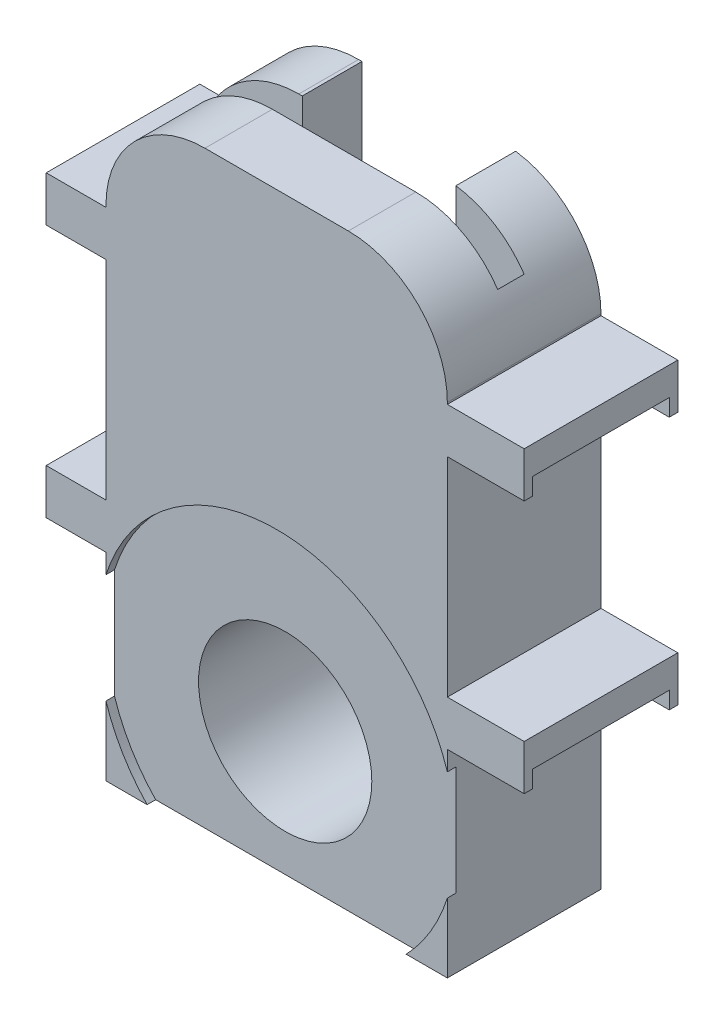
from build123d import *

# Parameters (mm, degrees)
SKETCH2_W           = 20
SKETCH2_H           = 35
BOSS_EXTRUDE1_DEPTH = 9
SKETCH3_W           = 9
SKETCH3_H           = 2.65
BOSS_EXTRUDE2_DEPTH = 14
SKETCH3_2_W         = 9
SKETCH3_2_H         = 2.65
BOSS_EXTRUDE3_DEPTH = 14
SKETCH4_R           = 5.075
CUT_EXTRUDE1_DEPTH  = 34.88300924
SKETCH5_R           = 10.5
CUT_EXTRUDE2_DEPTH  = 0.5
SKETCH7_W           = 18
SKETCH7_H           = 1.55
CUT_EXTRUDE3_DEPTH  = 22.2
SKETCH8_W           = 9
SKETCH8_H           = 3.5
CUT_EXTRUDE4_DEPTH  = 19
SKETCH9_W           = 3.2
SKETCH9_H           = 8
SKETCH9_W_2         = 4.2
CUT_EXTRUDE5_DEPTH  = 1
SKETCH10_W          = 3.2
SKETCH10_H          = 6.5
SKETCH10_W_2        = 4.2
SKETCH10_H_2        = 8
CUT_EXTRUDE6_DEPTH  = 1
CUT_EXTRUDE7_DEPTH  = 10


with BuildPart() as part:
    # Sketch2 → Boss-Extrude1 (new body)
    with BuildSketch(Plane.XY):
        with Locations((-6.829268293, 8.069105691)):
            Rectangle(SKETCH2_W, SKETCH2_H)
    extrude(amount=BOSS_EXTRUDE1_DEPTH)

    # Sketch3 → Boss-Extrude2 (add)
    with BuildSketch(Plane(origin=(-6.329268293, 0, 0), x_dir=(0, 0, -1), z_dir=(1, 0, 0))):
        with Locations((-4.5, 18.344105691)):
            Rectangle(SKETCH3_W, SKETCH3_H)
        with Locations((-4.5, 3.494105691)):
            Rectangle(SKETCH3_W, SKETCH3_H)
    extrude(amount=BOSS_EXTRUDE2_DEPTH)

    # Sketch3_2 → Boss-Extrude3 (add)
    with BuildSketch(Plane(origin=(-6.329268293, 0, 0), x_dir=(0, 0, -1), z_dir=(1, 0, 0))):
        with Locations((-4.5, 18.344105691)):
            Rectangle(SKETCH3_2_W, SKETCH3_2_H)
        with Locations((-4.5, 3.494105691)):
            Rectangle(SKETCH3_2_W, SKETCH3_2_H)
    extrude(amount=-BOSS_EXTRUDE3_DEPTH)

    # Sketch4 → Cut-Extrude1 (cut, through all)
    with BuildSketch(Plane.XY.offset(9)):
        with Locations((-6.829268293, -2.173702028)):
            Circle(SKETCH4_R)
    extrude(amount=-CUT_EXTRUDE1_DEPTH, mode=Mode.SUBTRACT)

    # Sketch5 → Cut-Extrude2 (cut)
    with BuildSketch(Plane.XY.offset(9)):
        with Locations((-6.829268293, -2.173702028)):
            Circle(SKETCH5_R)
    extrude(amount=-CUT_EXTRUDE2_DEPTH, mode=Mode.SUBTRACT)

    # Sketch7 → Cut-Extrude3 (cut)
    with BuildSketch(Plane(origin=(0, 25.569105691, 0), x_dir=(1, 0, 0), z_dir=(0, 1, 0))):
        with Locations((-6.829268293, -4.275)):
            Rectangle(SKETCH7_W, SKETCH7_H)
    extrude(amount=-CUT_EXTRUDE3_DEPTH, mode=Mode.SUBTRACT)

    # Sketch8 → Cut-Extrude4 (cut)
    with BuildSketch(Plane(origin=(0, 25.569105691, 0), x_dir=(1, 0, 0), z_dir=(0, 1, 0))):
        with Locations((-6.329268293, -1.75)):
            Rectangle(SKETCH8_W, SKETCH8_H)
    extrude(amount=-CUT_EXTRUDE4_DEPTH, mode=Mode.SUBTRACT)

    # Sketch9 → Cut-Extrude5 (cut)
    with BuildSketch(Plane.XZ.offset(-2.169105691)):
        with Locations((-18.729268293, 4.5)):
            Rectangle(SKETCH9_W, SKETCH9_H)
        with Locations((5.570731707, 4.5)):
            Rectangle(SKETCH9_W_2, SKETCH9_H)
    extrude(amount=-CUT_EXTRUDE5_DEPTH, mode=Mode.SUBTRACT)

    # Sketch10 → Cut-Extrude6 (cut)
    with BuildSketch(Plane.XZ.offset(-17.019105691)):
        with Locations((-18.729268293, 3.75)):
            Rectangle(SKETCH10_W, SKETCH10_H)
        with Locations((5.570731707, 4.5)):
            Rectangle(SKETCH10_W_2, SKETCH10_H_2)
    extrude(amount=-CUT_EXTRUDE6_DEPTH, mode=Mode.SUBTRACT)

    # Sketch13 → Cut-Extrude7 (cut)
    with BuildSketch(Plane.XY.offset(9)):
        with BuildLine():
            Line((3.170731707, 25.569105691), (-2.629268293, 25.569105691))
            ThreePointArc((-2.629268293, 25.569105691), (1.471951038, 23.870325022), (3.170731707, 19.769105691))
            Line((3.170731707, 19.769105691), (3.170731707, 25.569105691))
        make_face()
        with BuildLine():
            ThreePointArc((-16.829268293, 19.769105691), (-15.130487624, 23.870325022), (-11.029268293, 25.569105691))
            Line((-11.029268293, 25.569105691), (-16.829268293, 25.569105691))
            Line((-16.829268293, 25.569105691), (-16.829268293, 19.769105691))
        make_face()
    extrude(amount=-CUT_EXTRUDE7_DEPTH, mode=Mode.SUBTRACT)


solid = part.part
